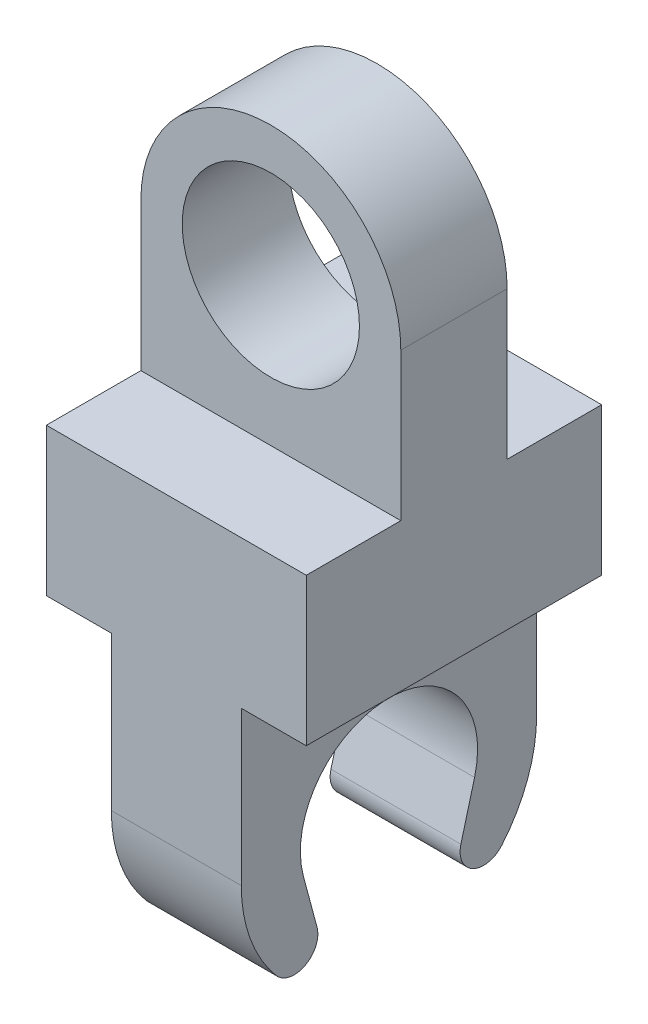
from build123d import *

# Parameters (mm, degrees)
BOSS_EXTRUDE2_DEPTH = 9
BOSS_EXTRUDE3_DEPTH = 22
BOSS_EXTRUDE5_START = -11
BOSS_EXTRUDE5_DEPTH = 22
SKETCH4_R           = 15
CUT_EXTRUDE1_DEPTH  = 44


with BuildPart() as part:
    # Sketch1 → Boss-Extrude2 (new body)
    with BuildSketch(Plane(origin=(0, 0, 0), x_dir=(0, 1, 0), z_dir=(0, 0, 1))):
        with BuildLine():
            Line((0, 22), (25, 22))
            ThreePointArc((25, 22), (47, 0), (25, -22))
            Line((25, -22), (0, -22))
            Line((0, -22), (0, 22))
        make_face()
    extrude(amount=BOSS_EXTRUDE2_DEPTH)

    # Sketch2 → Boss-Extrude3 (add, symmetric)
    with BuildSketch(Plane.YZ):
        Polygon((25, 0), (25, 9), (0, 9), (0, 25), (-25, 25), (-25, 0), (0, 0), align=None)
    extrude(amount=BOSS_EXTRUDE3_DEPTH, both=True)

    # Sketch3 → Boss-Extrude5 (add)
    with BuildSketch(Plane.YZ.offset(22).offset(BOSS_EXTRUDE5_START)):
        with BuildLine():
            Line((-25, 25), (-51, 25))
            ThreePointArc((-51, 25), (-59.593288161, 23.476699056), (-67.139363205, 19.092431886))
            ThreePointArc((-67.139363205, 19.092431886), (-68.101737646, 14.184187501), (-63.521788912, 12.173939479))
            Line((-63.521788912, 12.173939479), (-54.882285677, 14.488887394))
            ThreePointArc((-54.882285677, 14.488887394), (-41.868578565, 11.900300104), (-36, 0))
            Line((-36, 0), (-25, 0))
            Line((-25, 0), (-25, 25))
        make_face()
    extrude(amount=-BOSS_EXTRUDE5_DEPTH)

    # Mirror1: part across plane


with BuildPart() as part_1:
    add(part.part)
    add(part.part.mirror(Plane(origin=(0, 25, 0), x_dir=(1, 0, 0), z_dir=(0, 0, 1))))

    # Sketch4 → Cut-Extrude1 (cut)
    with BuildSketch(Plane.XY.offset(9)):
        with Locations((0, 25)):
            Circle(SKETCH4_R)
    extrude(amount=-CUT_EXTRUDE1_DEPTH, mode=Mode.SUBTRACT)


solid = part_1.part
